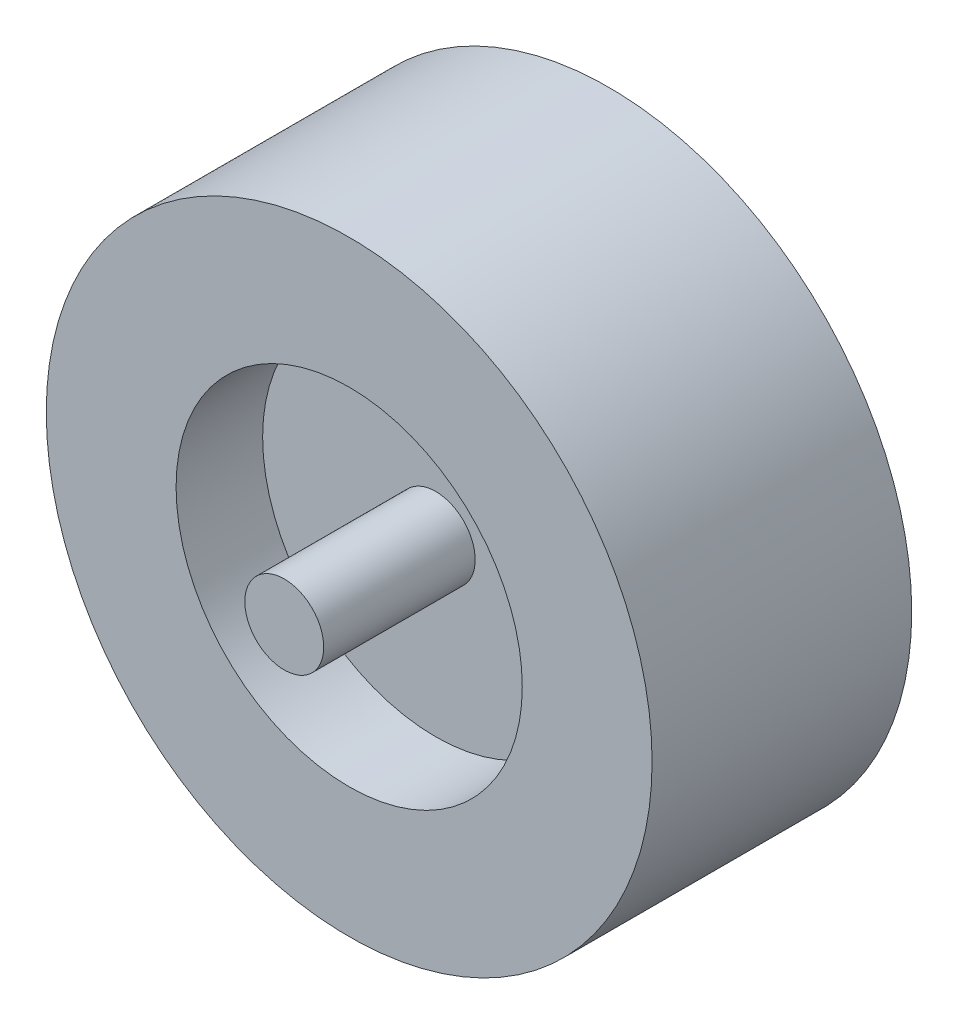
from build123d import *

# Parameters (mm, degrees)
SKETCH4_R           = 17.36725
BOSS_EXTRUDE1_DEPTH = 85.725


with BuildPart() as part:
    # Sketch1 → Revolve1 (revolve)
    with BuildSketch(Plane(origin=(0, 0, 0), x_dir=(0, 0, -1), z_dir=(1, 0, 0))):
        Polygon((-57.15, 76.2), (-57.15, 133.35), (57.15, 133.35), (57.15, 76.2), (19.05, 76.2), (19.05, 0), (-19.05, 0), (-19.05, 76.2), align=None)
    revolve(axis=Axis((0, 0, 19.05), (0, 0, -1)))

    # Sketch4 → Boss-Extrude1 (add, symmetric)
    with BuildSketch(Plane(origin=(0, 0, 0), x_dir=(-1, 0, 0), z_dir=(0, 0, -1))):
        Circle(SKETCH4_R)
    extrude(amount=BOSS_EXTRUDE1_DEPTH, both=True)


solid = part.part
